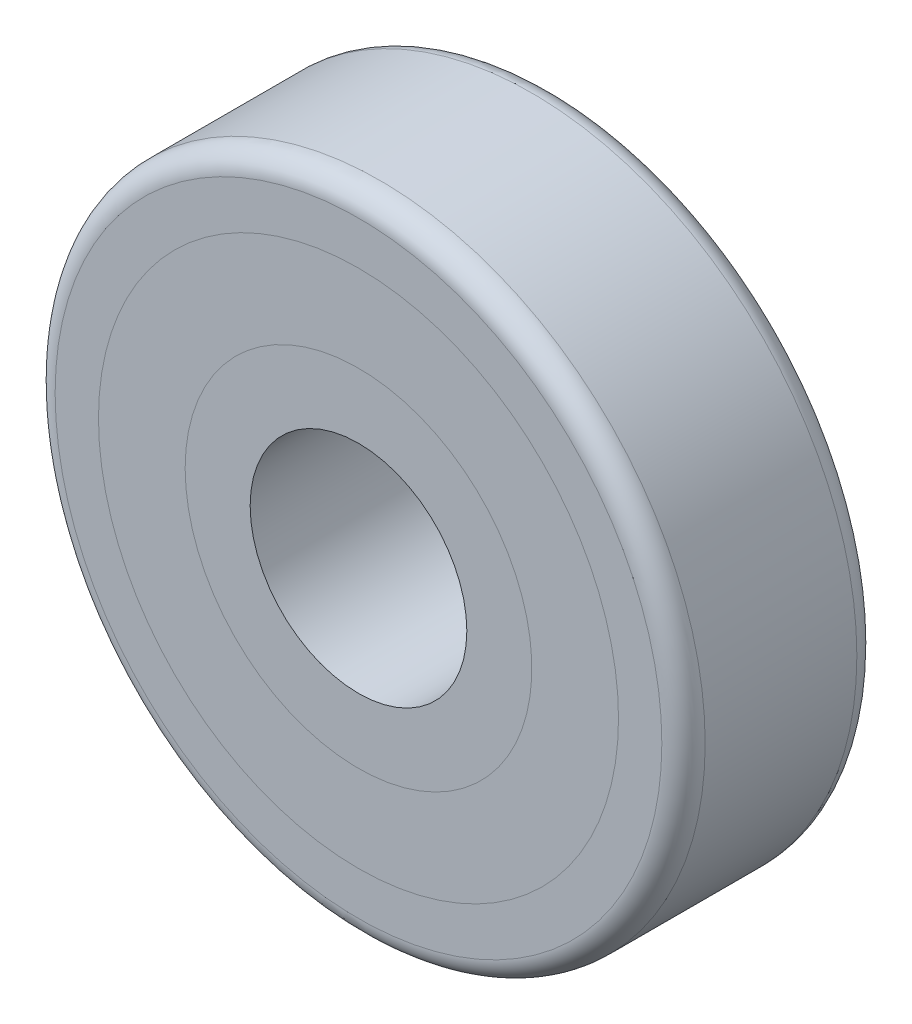
from build123d import *

# Parameters (mm, degrees)
SKETCH1_R           = 15
SKETCH1_R_2         = 12
BOSS_EXTRUDE1_DEPTH = 9
SKETCH2_R           = 8
SKETCH2_R_2         = 5
BOSS_EXTRUDE2_DEPTH = 9
SKETCH3_R           = 12
SKETCH3_R_2         = 8
BOSS_EXTRUDE3_DEPTH = 9
FILLET1_R           = 1


with BuildPart() as part:
    # Sketch1 → Boss-Extrude1 (new body)
    with BuildSketch(Plane.XY):
        Circle(SKETCH1_R)
        Circle(SKETCH1_R_2, mode=Mode.SUBTRACT)
    extrude(amount=BOSS_EXTRUDE1_DEPTH)

    # Fillet1
    fillet1_edges = [part.edges().sort_by_distance(p)[0] for p in [
        (-15, 0, 0),
        (-15, 0, 9),
    ]]
    fillet(fillet1_edges, radius=FILLET1_R)


with BuildPart() as body_2:
    # Sketch2 → Boss-Extrude2 (new body)
    with BuildSketch(Plane(origin=(0, 0, 0), x_dir=(-1, 0, 0), z_dir=(0, 0, -1))):
        Circle(SKETCH2_R)
        Circle(SKETCH2_R_2, mode=Mode.SUBTRACT)
    extrude(amount=-BOSS_EXTRUDE2_DEPTH)


with BuildPart() as body_3:
    # Sketch3 → Boss-Extrude3 (new body)
    with BuildSketch(Plane(origin=(0, 0, 0), x_dir=(-1, 0, 0), z_dir=(0, 0, -1))):
        Circle(SKETCH3_R)
        Circle(SKETCH3_R_2, mode=Mode.SUBTRACT)
    extrude(amount=-BOSS_EXTRUDE3_DEPTH)


solid = Compound([part.part, body_2.part, body_3.part])
